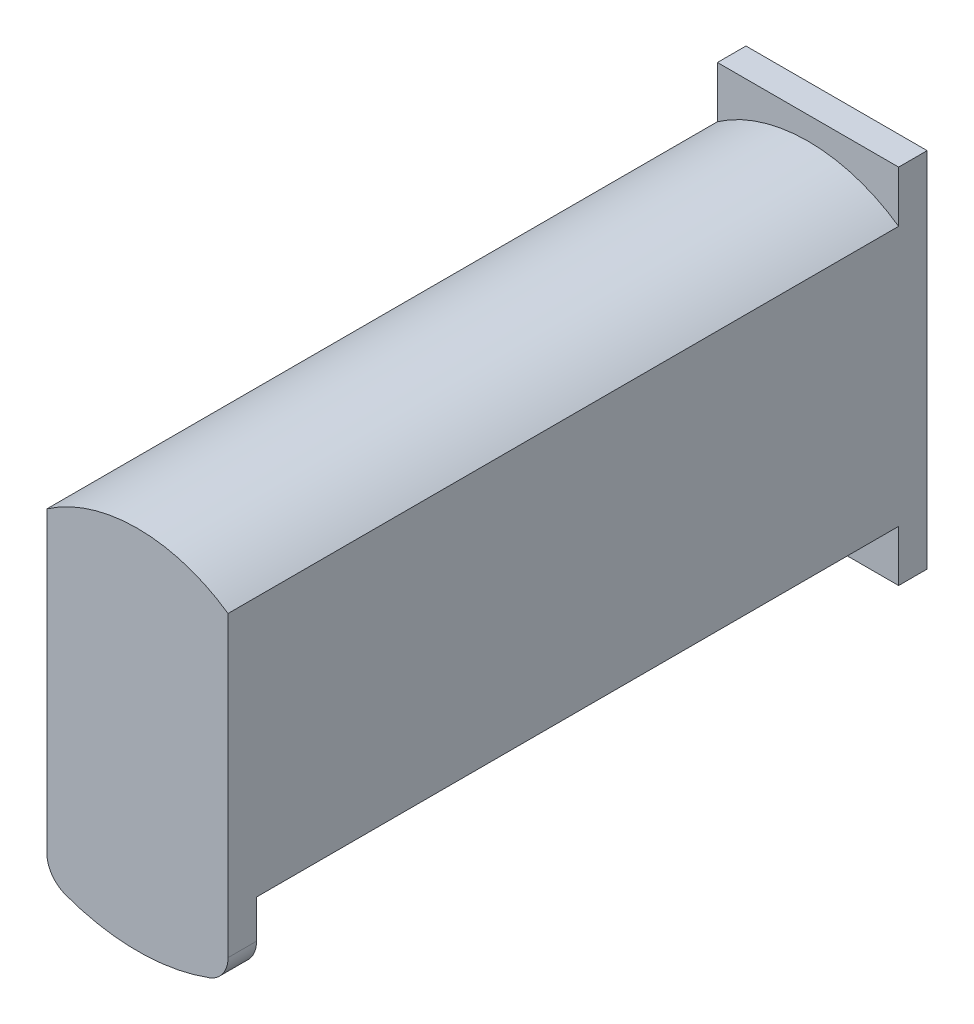
from build123d import *

# Parameters (mm, degrees)
SKETCH2_W           = 25.4
SKETCH2_H           = 50.8
SKETCH2_R           = 3.5
BOSS_EXTRUDE4_DEPTH = 4
BOSS_EXTRUDE5_START = 4
BOSS_EXTRUDE5_DEPTH = 90
CUT_EXTRUDE2_START  = 8
SKETCH2_6_W         = 11.5
SKETCH2_6_H         = 13
CUT_EXTRUDE2_DEPTH  = 6
SKETCH2_7_R         = 3.5
CUT_EXTRUDE3_DEPTH  = 25
BOSS_EXTRUDE6_DEPTH = 4
FILLET1_R           = 4


with BuildPart() as part:
    # Sketch2 → Boss-Extrude4 (new body)
    with BuildSketch(Plane.XY):
        Rectangle(SKETCH2_W, SKETCH2_H)
        with Locations((0, 12.7)):
            Circle(SKETCH2_R, mode=Mode.SUBTRACT)
        with Locations((0, -12.7)):
            Circle(SKETCH2_R, mode=Mode.SUBTRACT)
    extrude(amount=BOSS_EXTRUDE4_DEPTH)

    # Sketch2_4 → Boss-Extrude5 (add)
    with BuildSketch(Plane.XY.offset(BOSS_EXTRUDE5_START)):
        with BuildLine():
            Line((12.7, -12.7), (5.75, -12.7))
            Line((5.75, -12.7), (5.75, -19.2))
            Line((5.75, -19.2), (-5.75, -19.2))
            Line((-5.75, -19.2), (-5.75, -12.7))
            Line((-5.75, -12.7), (-12.7, -12.7))
            Line((-12.7, -12.7), (-12.7, -18.208514492))
            ThreePointArc((-12.7, -18.208514492), (0, -22.2), (12.7, -18.208514492))
            Line((12.7, -18.208514492), (12.7, -12.7))
        make_face()
        with BuildLine():
            Line((5.75, -19.2), (5.75, -12.7))
            Line((5.75, -12.7), (3.5, -12.7))
            ThreePointArc((3.5, -12.7), (0, -16.2), (-3.5, -12.7))
            Line((-3.5, -12.7), (-5.75, -12.7))
            Line((-5.75, -12.7), (-5.75, -19.2))
            Line((-5.75, -19.2), (5.75, -19.2))
        make_face()
        with BuildLine():
            Line((5.75, -12.7), (5.75, -6.2))
            Line((5.75, -6.2), (-5.75, -6.2))
            Line((-5.75, -6.2), (-5.75, -12.7))
            Line((-5.75, -12.7), (-3.5, -12.7))
            ThreePointArc((-3.5, -12.7), (0, -9.2), (3.5, -12.7))
            Line((3.5, -12.7), (5.75, -12.7))
        make_face()
        with BuildLine():
            ThreePointArc((-3.5, -12.7), (0, -16.2), (3.5, -12.7))
            Line((3.5, -12.7), (-3.5, -12.7))
        make_face()
        with BuildLine():
            Line((-3.5, -12.7), (3.5, -12.7))
            ThreePointArc((3.5, -12.7), (0, -9.2), (-3.5, -12.7))
        make_face()
        with BuildLine():
            ThreePointArc((-3.5, 12.7), (0, 9.2), (3.5, 12.7))
            Line((3.5, 12.7), (-3.5, 12.7))
        make_face()
        with BuildLine():
            Line((-3.5, 12.7), (3.5, 12.7))
            ThreePointArc((3.5, 12.7), (0, 16.2), (-3.5, 12.7))
        make_face()
        with BuildLine():
            Line((3.5, 12.7), (5.75, 12.7))
            Line((5.75, 12.7), (5.75, 19.2))
            Line((5.75, 19.2), (-5.75, 19.2))
            Line((-5.75, 19.2), (-5.75, 12.7))
            Line((-5.75, 12.7), (-3.5, 12.7))
            ThreePointArc((-3.5, 12.7), (0, 16.2), (3.5, 12.7))
        make_face()
        with BuildLine():
            Line((5.75, 6.2), (5.75, 12.7))
            Line((5.75, 12.7), (3.5, 12.7))
            ThreePointArc((3.5, 12.7), (0, 9.2), (-3.5, 12.7))
            Line((-3.5, 12.7), (-5.75, 12.7))
            Line((-5.75, 12.7), (-5.75, 6.2))
            Line((-5.75, 6.2), (5.75, 6.2))
        make_face()
        Polygon((-5.75, -6.2), (5.75, -6.2), (5.75, -12.7), (12.7, -12.7), (12.7, 12.7), (5.75, 12.7), (5.75, 6.2), (-5.75, 6.2), (-5.75, 12.7), (-12.7, 12.7), (-12.7, -12.7), (-5.75, -12.7), align=None)
        with BuildLine():
            Line((5.75, 12.7), (12.7, 12.7))
            Line((12.7, 12.7), (12.7, 18.208514492))
            ThreePointArc((12.7, 18.208514492), (0, 22.2), (-12.7, 18.208514492))
            Line((-12.7, 18.208514492), (-12.7, 12.7))
            Line((-12.7, 12.7), (-5.75, 12.7))
            Line((-5.75, 12.7), (-5.75, 19.2))
            Line((-5.75, 19.2), (5.75, 19.2))
            Line((5.75, 19.2), (5.75, 12.7))
        make_face()
    extrude(amount=BOSS_EXTRUDE5_DEPTH)

    # Sketch2_6 → Cut-Extrude2 (cut)
    with BuildSketch(Plane.XY.offset(CUT_EXTRUDE2_START)):
        with Locations((0, -12.7)):
            Rectangle(SKETCH2_6_W, SKETCH2_6_H)
        with Locations((0, 12.7)):
            Rectangle(SKETCH2_6_W, SKETCH2_6_H)
    extrude(amount=CUT_EXTRUDE2_DEPTH, mode=Mode.SUBTRACT)

    # Sketch2_7 → Cut-Extrude3 (cut)
    with BuildSketch(Plane.XY):
        with Locations((0, 12.7)):
            Circle(SKETCH2_7_R)
        with Locations((0, -12.7)):
            Circle(SKETCH2_7_R)
    extrude(amount=CUT_EXTRUDE3_DEPTH, mode=Mode.SUBTRACT)

    # Sketch3 → Boss-Extrude6 (add)
    with BuildSketch(Plane.XY.offset(94)):
        with BuildLine():
            Line((12.7, -18.208514492), (12.7, -26.208514492))
            ThreePointArc((12.7, -26.208514492), (0, -29.123465314), (-12.7, -26.208514492))
            Line((-12.7, -26.208514492), (-12.7, -18.208514492))
            Line((-12.7, -18.208514492), (-12.7, 18.208514492))
            ThreePointArc((-12.7, 18.208514492), (0, 22.2), (12.7, 18.208514492))
            Line((12.7, 18.208514492), (12.7, -18.208514492))
        make_face()
    extrude(amount=BOSS_EXTRUDE6_DEPTH)

    # Fillet1
    fillet1_edges = [part.edges().sort_by_distance(p)[0] for p in [
        (12.7, -26.208514492, 96),
        (-12.7, -26.208514492, 96),
    ]]
    fillet(fillet1_edges, radius=FILLET1_R)


solid = part.part
